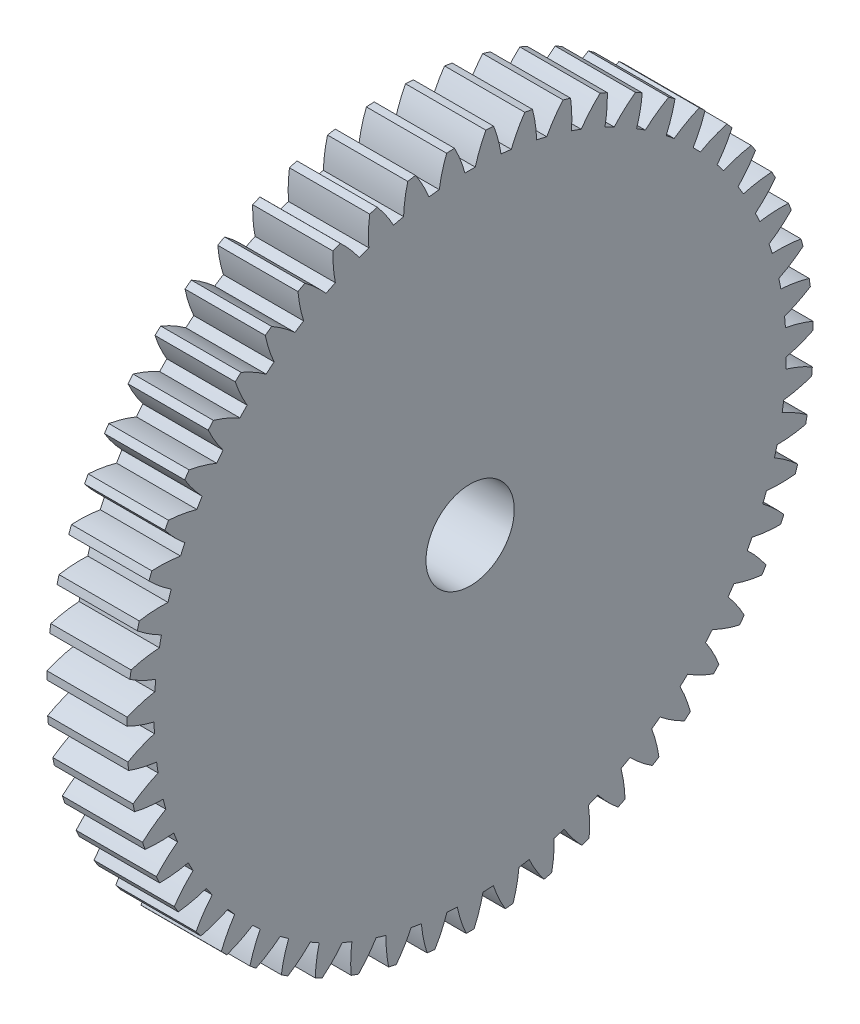
from build123d import *

# Parameters (mm, degrees)
BASPROSKE_W                 = 10
BASPROSKE_H                 = 42.75
TOOTHCUT_DEPTH              = 62.279074732
TEETHCUTS_COUNT             = 55
TEETHCUTS_ANGLE             = 353.454545455
HUBNEAONESKE_R              = 14
HUBNEARONE_DEPTH            = 15.0000508
BORSKE_R                    = 6
BORE_DEPTH                  = 25.0000508
IZIM1_R                     = 14
IZIM1_R_2                   = 11
KES_EKSTR_ZYON1_DEPTH       = 15.0000508
IZIM2_R                     = 6
IZIM2_R_2                   = 5.5
Y_KSEKLIK_EKSTR_ZYON1_DEPTH = 25.0000508


with BuildPart() as part:
    # BasProSke → Base-Revolve (revolve)
    with BuildSketch(Plane(origin=(0, 0, 0), x_dir=(1, 0, 0), z_dir=(0, 1, 0)), mode=Mode.PRIVATE) as base_revolve_sk:
        with Locations((5, 21.375)):
            Rectangle(BASPROSKE_W, BASPROSKE_H)
    revolve(base_revolve_sk.sketch.rotate(Axis((-10, 0, 0), (1, 0, 0)), 180), axis=Axis((-10, 0, 0), (1, 0, 0)))

    # TooCutSke → ToothCut (cut, through all)
    with BuildSketch(Plane(origin=(0, 0, 0), x_dir=(0, 0, -1), z_dir=(1, 0, 0))):
        with BuildLine():
            ThreePointArc((0.643828179, 39.368735835), (0, 39.374), (-0.643828179, 39.368735835))
            ThreePointArc((-0.643828179, 39.368735835), (-1.212962743, 41.08576087), (-1.966631281, 42.730167406))
            ThreePointArc((-1.966631281, 42.730167406), (0, 42.7754), (1.966631281, 42.730167406))
            ThreePointArc((1.966631281, 42.730167406), (1.212962743, 41.08576087), (0.643828179, 39.368735835))
        make_face()
    toothcut = extrude(amount=TOOTHCUT_DEPTH, mode=Mode.SUBTRACT)

    # TeethCuts: ToothCut ×55 about axis
    teethcuts_axis = Axis((-10, 0, 0), (1, 0, 0))
    for i in range(1, TEETHCUTS_COUNT):
        add(toothcut.rotate(teethcuts_axis, i * TEETHCUTS_ANGLE / (TEETHCUTS_COUNT - 1)), mode=Mode.SUBTRACT)

    # HubNeaOneSke → HubNearOne (add)
    with BuildSketch(Plane.ZY):
        with Locations(Location((0, 0, 0), (0, 0, 180))):
            Circle(HUBNEAONESKE_R)
    extrude(amount=HUBNEARONE_DEPTH)

    # BorSke → Bore (cut, symmetric)
    with BuildSketch(Plane(origin=(0, 0, 0), x_dir=(0, 0, -1), z_dir=(1, 0, 0))):
        with Locations(Location((0, 0, 0), (0, 0, 180))):
            Circle(BORSKE_R)
    extrude(amount=BORE_DEPTH, both=True, mode=Mode.SUBTRACT)

    # Çizim1 → Kes-Ekstrüzyon1 (cut)
    with BuildSketch(Plane.ZY.offset(15.0000508)):
        Circle(IZIM1_R)
        Circle(IZIM1_R_2, mode=Mode.SUBTRACT)
    extrude(amount=-KES_EKSTR_ZYON1_DEPTH, mode=Mode.SUBTRACT)

    # Çizim2 → Yükseklik-Ekstrüzyon1 (add)
    with BuildSketch(Plane.ZY.offset(15.0000508)):
        Circle(IZIM2_R)
        Circle(IZIM2_R_2, mode=Mode.SUBTRACT)
    extrude(amount=-Y_KSEKLIK_EKSTR_ZYON1_DEPTH)


solid = part.part
